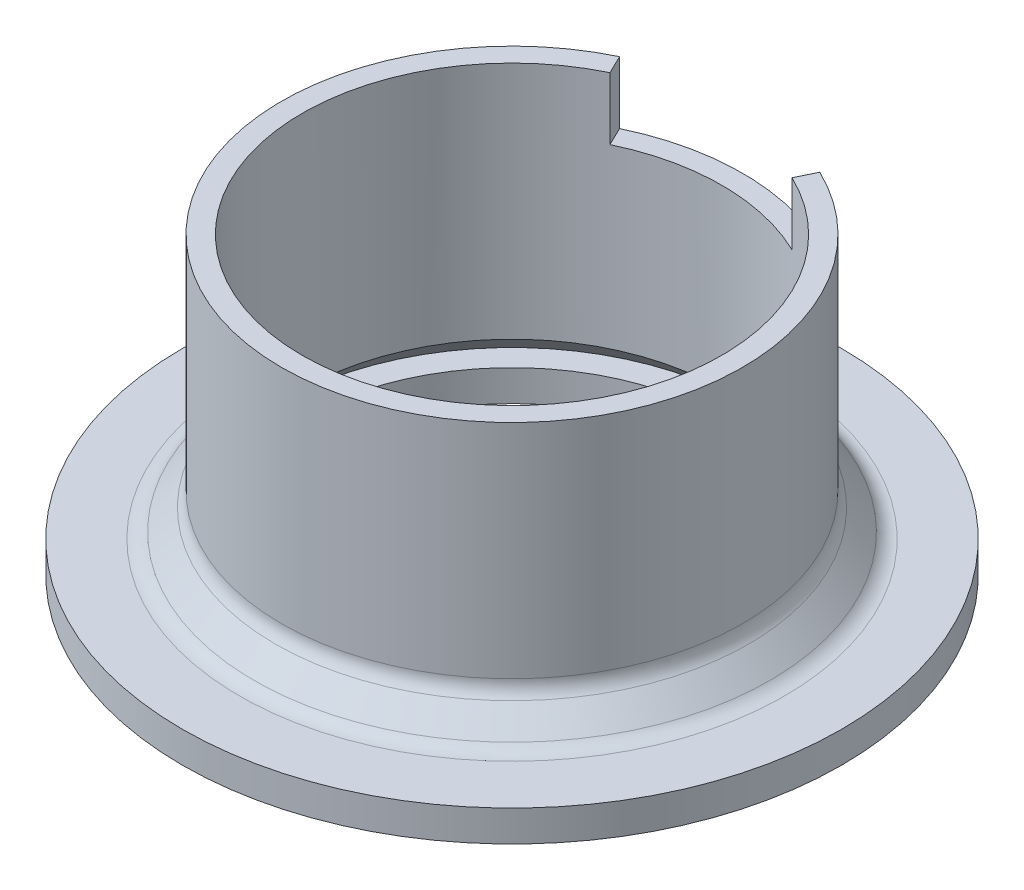
from build123d import *

# Parameters (mm, degrees)
SKETCH4_R           = 31.75
SKETCH4_R_2         = 20.2
BOSS_EXTRUDE1_DEPTH = 3
FILLET1_R           = 2
FILLET2_R           = 2
BOSS_EXTRUDE2_DEPTH = 1
CIRPATTERN1_COUNT   = 4
CUT_EXTRUDE1_DEPTH  = 6
CUT_EXTRUDE2_DEPTH  = 6


with BuildPart() as part:
    # Sketch3 → Revolve1 (revolve)
    with BuildSketch(Plane.XY):
        Polygon((-20.2, 25.4), (-22.2, 25.4), (-22.2, 3.2), (-25.4, 0), (-22.571572875, 0), (-20.2, 2.371572875), align=None)
    revolve(axis=Axis((0, 25.4, 0), (0, -1, 0)))

    # Sketch4 → Boss-Extrude1 (add)
    with BuildSketch(Plane.XZ):
        Circle(SKETCH4_R)
        Circle(SKETCH4_R_2, mode=Mode.SUBTRACT)
    extrude(amount=BOSS_EXTRUDE1_DEPTH)

    # Fillet1
    fillet1_edges = [part.edges().sort_by_distance(p)[0] for p in [
        (25.4, 0, 0),
    ]]
    fillet(fillet1_edges, radius=FILLET1_R)

    # Fillet2
    fillet2_edges = [part.edges().sort_by_distance(p)[0] for p in [
        (22.2, 3.2, 0),
    ]]
    fillet(fillet2_edges, radius=FILLET2_R)

    # Sketch5 → Boss-Extrude2 (add, symmetric)
    with BuildSketch(Plane.XY):
        Polygon((20.2, 0), (23.444013634, 0), (23.444013634, 1.439043573), (20.2, 4.645223745), align=None)
    boss_extrude2 = extrude(amount=BOSS_EXTRUDE2_DEPTH, both=True)

    # CirPattern1: Boss-Extrude2 ×4 about axis
    cirpattern1_axis = Axis((0, 25.4, 0), (0, 1, 0))
    for i in range(1, CIRPATTERN1_COUNT):
        add(boss_extrude2.rotate(cirpattern1_axis, i * 360 / CIRPATTERN1_COUNT))

    # Sketch6 → Cut-Extrude1 (cut)
    with BuildSketch(Plane(origin=(0, 25.4, 0), x_dir=(1, 0, 0), z_dir=(0, 1, 0))):
        with BuildLine():
            Line((0, 20), (-13.834891336, 20))
            ThreePointArc((-13.834891336, 20), (0, 24.318803801), (13.834891336, 20))
            Line((13.834891336, 20), (0, 20))
        make_face()
    extrude(amount=-CUT_EXTRUDE1_DEPTH, mode=Mode.SUBTRACT)

    # Sketch7 → Cut-Extrude2 (cut)
    with BuildSketch(Plane(origin=(0, 25.4, 0), x_dir=(1, 0, 0), z_dir=(0, 1, 0))):
        Polygon((-9.635351576, 20), (2.835489376, 20), (9.635351576, 20), (7.753188698, 16.093213904), (-7.753188698, 16.093213904), align=None)
    extrude(amount=-CUT_EXTRUDE2_DEPTH, mode=Mode.SUBTRACT)


solid = part.part
